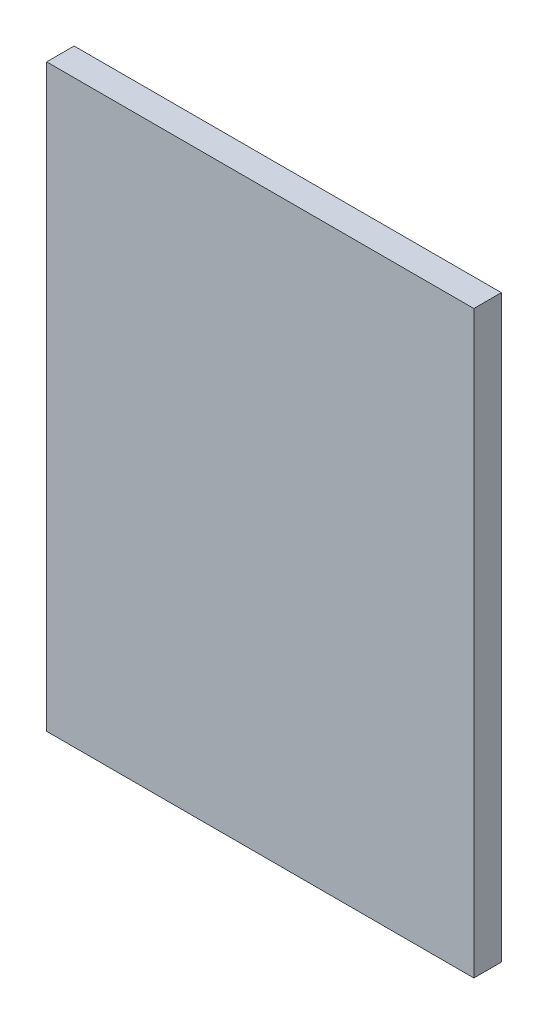
from build123d import *

# Parameters (mm, degrees)
SKETCH1_W           = 280
SKETCH1_H           = 380
BOSS_EXTRUDE1_DEPTH = 18


with BuildPart() as part:
    # Sketch1 → Boss-Extrude1 (new body)
    with BuildSketch(Plane.XY):
        Rectangle(SKETCH1_W, SKETCH1_H)
    extrude(amount=BOSS_EXTRUDE1_DEPTH)


solid = part.part
